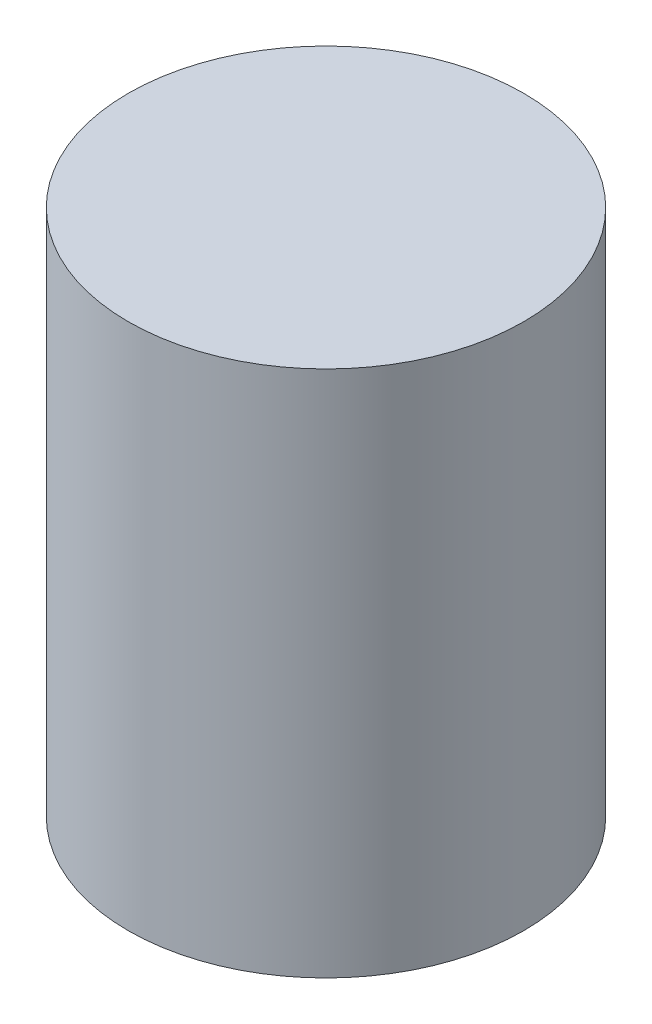
from build123d import *

# Parameters (mm, degrees)
SWEEP1_PROFILE_R = 1.5


with BuildPart() as part:
    # Sweep1: sweep along a path in Sketch1
    with BuildLine(Plane.XY) as sweep1_path:
        Line((0, 0), (0, 4))
    # Sweep1 profile (on start of the path) → Sweep1 (sweep)
    with BuildSketch(Plane.ZX):
        Circle(SWEEP1_PROFILE_R)
    sweep(path=sweep1_path.line)


solid = part.part
